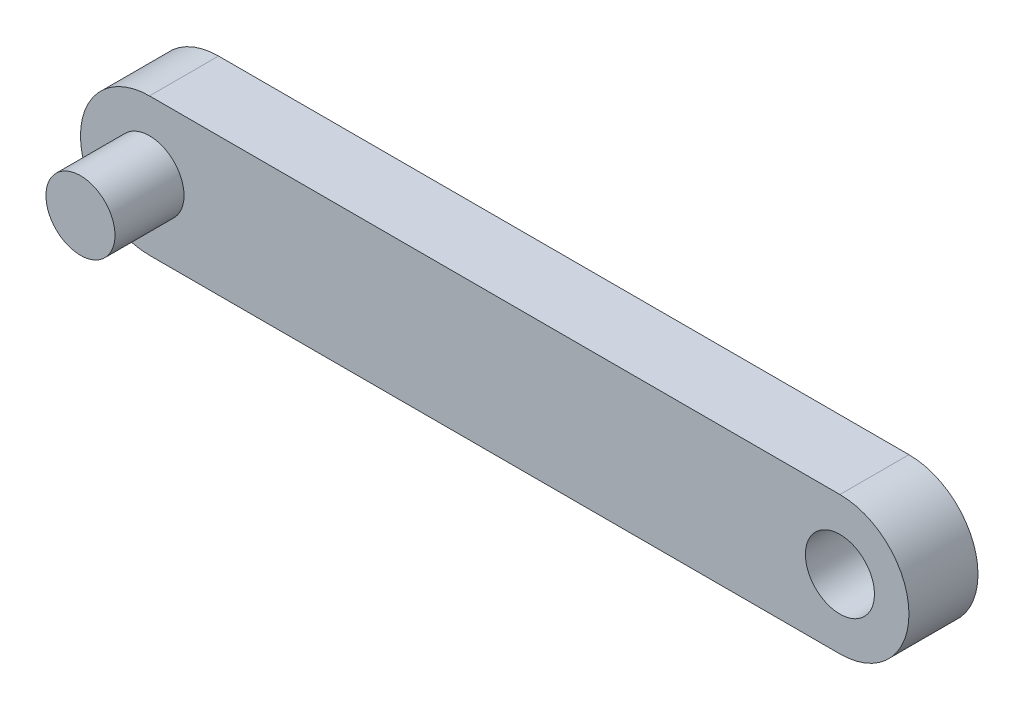
from build123d import *

# Parameters (mm, degrees)
SKETCH1_R           = 2.5
BOSS_EXTRUDE1_DEPTH = 5
SKETCH1_2_R         = 2.5
BOSS_EXTRUDE2_DEPTH = 10


with BuildPart() as part:
    # Sketch1 → Boss-Extrude1 (new body)
    with BuildSketch(Plane.XY):
        with BuildLine():
            Line((-25, 5), (25, 5))
            ThreePointArc((25, 5), (30, 0), (25, -5))
            Line((25, -5), (-25, -5))
            ThreePointArc((-25, -5), (-30, 0), (-25, 5))
        make_face()
        with Locations((-25, 0)):
            Circle(SKETCH1_R, mode=Mode.SUBTRACT)
        with Locations((25, 0)):
            Circle(SKETCH1_R, mode=Mode.SUBTRACT)
    extrude(amount=BOSS_EXTRUDE1_DEPTH)

    # Sketch1_2 → Boss-Extrude2 (add)
    with BuildSketch(Plane.XY):
        with Locations((-25, 0)):
            Circle(SKETCH1_2_R)
    extrude(amount=BOSS_EXTRUDE2_DEPTH)


solid = part.part
